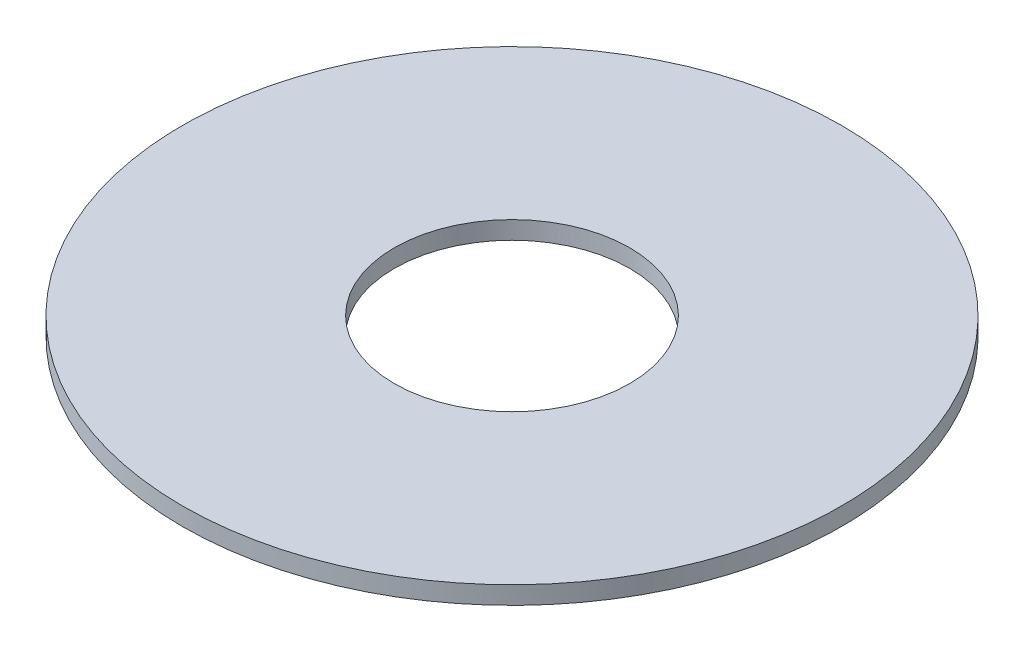
from build123d import *

# Parameters (mm, degrees)
SKETCH1_R           = 35
SKETCH1_R_2         = 12.5
BOSS_EXTRUDE1_DEPTH = 1.9


with BuildPart() as part:
    # Sketch1 → Boss-Extrude1 (new body)
    with BuildSketch(Plane(origin=(0, 0, 0), x_dir=(1, 0, 0), z_dir=(0, 1, 0))):
        Circle(SKETCH1_R)
        Circle(SKETCH1_R_2, mode=Mode.SUBTRACT)
    extrude(amount=BOSS_EXTRUDE1_DEPTH)


solid = part.part
